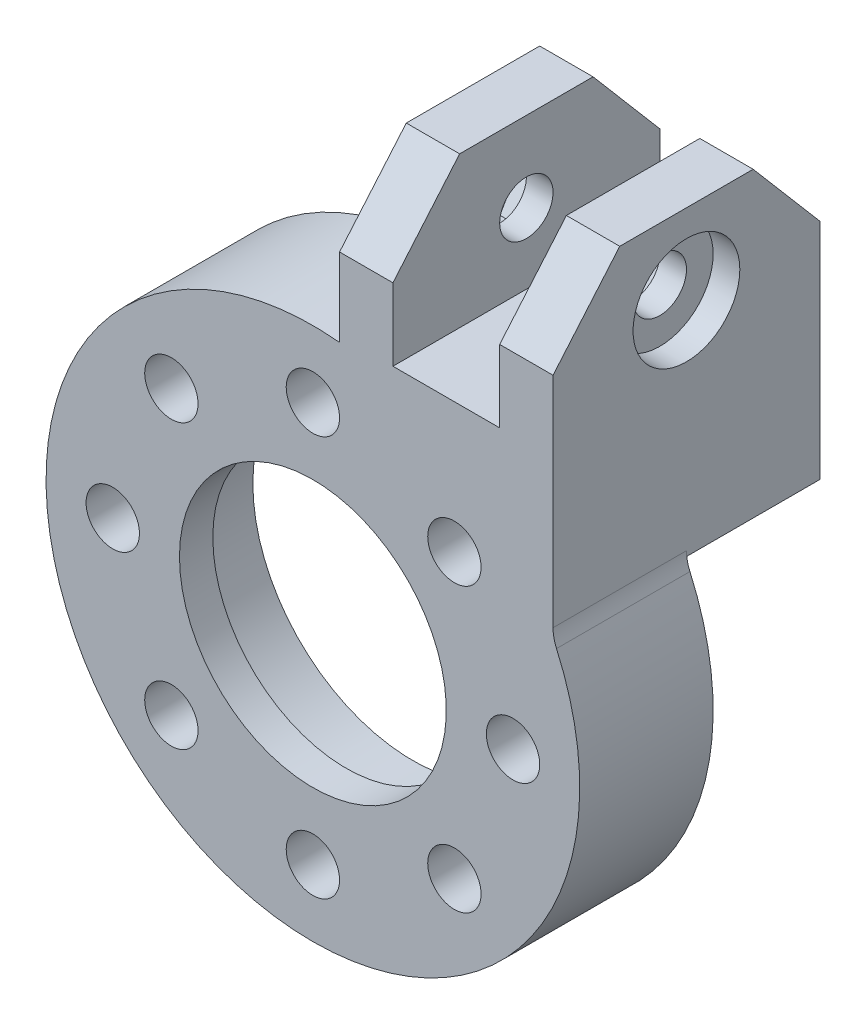
from build123d import *

# Parameters (mm, degrees)
SKETCH1_R               = 20
SKETCH1_R_2             = 15
BOSS_EXTRUDE1_DEPTH     = 10
BOSS_EXTRUDE2_DEPTH     = 20
SKETCH3_W               = 4
SKETCH3_H               = 31.92260483
BOSS_EXTRUDE4_DEPTH     = 20
BOSS_EXTRUDE5_DEPTH     = 20
SKETCH4_R               = 20
CUT_EXTRUDE1_DEPTH      = 11
CUT_EXTRUDE2_DEPTH      = 39
CUT_EXTRUDE3_DEPTH      = 39
SKETCH8_R               = 2
CUT_EXTRUDE4_DEPTH      = 39
FILLET4_R               = 3
SKETCH9_W               = 21.007104118
SKETCH9_H               = 10.314289307
CUT_EXTRUDE5_DEPTH      = 3
CUT_EXTRUDE5_DEPTH_BACK = 39
CUT_EXTRUDE6_DEPTH      = 19
CUT_EXTRUDE7_DEPTH      = 19
SKETCH12_R              = 4
CUT_EXTRUDE8_DEPTH      = 2
CUT_EXTRUDE9_DEPTH      = 2
BOSS_EXTRUDE7_DEPTH     = 20
SKETCH19_R              = 20.125
CUT_EXTRUDE11_DEPTH     = 11
SKETCH20_R              = 15
SKETCH20_R_2            = 12
BOSS_EXTRUDE8_DEPTH     = 10
SKETCH21_R              = 12
BOSS_EXTRUDE9_DEPTH     = 2.5
SKETCH22_R              = 10
CUT_EXTRUDE12_DEPTH     = 2.5
SKETCH23_R              = 17.5
CUT_EXTRUDE13_DEPTH     = 2.5
SKETCH24_R              = 2
CUT_EXTRUDE14_DEPTH     = 8.5


with BuildPart() as part:
    # Sketch1 → Boss-Extrude1 (new body)
    with BuildSketch(Plane.XY):
        Circle(SKETCH1_R)
        Circle(SKETCH1_R_2, mode=Mode.SUBTRACT)
    extrude(amount=BOSS_EXTRUDE1_DEPTH)

    # Sketch2 → Boss-Extrude2 (add)
    with BuildSketch(Plane.XY.offset(10)):
        with BuildLine():
            Line((2, 39.866068747), (2, 19.899748742))
            ThreePointArc((2, 19.899748742), (4.02100681, 19.591618214), (6, 19.078784028))
            Line((6, 19.078784028), (6, 39.866068747))
            Line((6, 39.866068747), (2, 39.866068747))
        make_face()
    extrude(amount=-BOSS_EXTRUDE2_DEPTH)

    # Sketch3 → Boss-Extrude4 (add)
    with BuildSketch(Plane.XY.offset(10)):
        with Locations((16, 24.679100302)):
            Rectangle(SKETCH3_W, SKETCH3_H)
    extrude(amount=-BOSS_EXTRUDE4_DEPTH)

    # Sketch5 → Boss-Extrude5 (add)
    with BuildSketch(Plane.XY.offset(10)):
        Polygon((14, 20.353512461), (10.603962903, 16.957475365), (14, 14.282856857), align=None)
    extrude(amount=-BOSS_EXTRUDE5_DEPTH)

    # Sketch4 → Cut-Extrude1 (cut, through all)
    with BuildSketch(Plane(origin=(0, 0, 0), x_dir=(-1, 0, 0), z_dir=(0, 0, -1))):
        Circle(SKETCH4_R)
    extrude(amount=CUT_EXTRUDE1_DEPTH, mode=Mode.SUBTRACT)

    # Sketch6 → Cut-Extrude2 (cut, through all)
    with BuildSketch(Plane(origin=(18, 0, 0), x_dir=(0, 0, -1), z_dir=(1, 0, 0))):
        Polygon((-10, 40.640402717), (-6, 40.640402717), (-10, 36.640402717), align=None)
    extrude(amount=-CUT_EXTRUDE2_DEPTH, mode=Mode.SUBTRACT)

    # Sketch7 → Cut-Extrude3 (cut, through all)
    with BuildSketch(Plane(origin=(18, 0, 0), x_dir=(0, 0, -1), z_dir=(1, 0, 0))):
        Polygon((10, 40.640402717), (6, 40.640402717), (10, 36.640402717), align=None)
    extrude(amount=-CUT_EXTRUDE3_DEPTH, mode=Mode.SUBTRACT)

    # Sketch8 → Cut-Extrude4 (cut, through all)
    with BuildSketch(Plane(origin=(18, 0, 0), x_dir=(0, 0, -1), z_dir=(1, 0, 0))):
        with Locations((0, 25.640402717)):
            Circle(SKETCH8_R)
    extrude(amount=-CUT_EXTRUDE4_DEPTH, mode=Mode.SUBTRACT)

    # Fillet4
    fillet4_edges = [part.edges().sort_by_distance(p)[0] for p in [
        (18, 8.717797887, 5),
    ]]
    fillet(fillet4_edges, radius=FILLET4_R)

    # Sketch9 → Cut-Extrude5 (cut, two sides)
    with BuildSketch(Plane(origin=(18, 0, 0), x_dir=(0, 0, -1), z_dir=(1, 0, 0))) as cut_extrude5_sk:
        with Locations((0.503552059, 36.79754737)):
            Rectangle(SKETCH9_W, SKETCH9_H)
    extrude(amount=CUT_EXTRUDE5_DEPTH, mode=Mode.SUBTRACT)
    extrude(cut_extrude5_sk.sketch, amount=-CUT_EXTRUDE5_DEPTH_BACK, mode=Mode.SUBTRACT)

    # Sketch10 → Cut-Extrude6 (cut, through all)
    with BuildSketch(Plane.ZY.offset(-2)):
        Polygon((10, 31.640402717), (5, 31.640402717), (10, 25.770075729), align=None)
    extrude(amount=-CUT_EXTRUDE6_DEPTH, mode=Mode.SUBTRACT)

    # Sketch11 → Cut-Extrude7 (cut, through all)
    with BuildSketch(Plane.ZY.offset(-2)):
        Polygon((-10, 31.640402717), (-10, 25.770075729), (-5, 31.640402717), align=None)
    extrude(amount=-CUT_EXTRUDE7_DEPTH, mode=Mode.SUBTRACT)

    # Sketch12 → Cut-Extrude8 (cut)
    with BuildSketch(Plane(origin=(18, 0, 0), x_dir=(0, 0, -1), z_dir=(1, 0, 0))):
        with Locations((0, 25.640402717)):
            Circle(SKETCH12_R)
    extrude(amount=-CUT_EXTRUDE8_DEPTH, mode=Mode.SUBTRACT)

    # Sketch13 → Cut-Extrude9 (cut)
    with BuildSketch(Plane.ZY.offset(-2)):
        Polygon((4.041451884, 25.640402717), (2.020725942, 29.140402717), (-2.020725942, 29.140402717), (-4.041451884, 25.640402717), (-2.020725942, 22.140402717), (2.020725942, 22.140402717), align=None)
    extrude(amount=-CUT_EXTRUDE9_DEPTH, mode=Mode.SUBTRACT)

    # Sketch16 → Boss-Extrude7 (add)
    with BuildSketch(Plane.XY.offset(10)):
        with BuildLine():
            Line((14, 20.353512461), (6, 20.353512461))
            Line((6, 20.353512461), (6, 19.078784028))
            ThreePointArc((6, 19.078784028), (8.369461371, 18.164584123), (10.603962903, 16.957475365))
            Line((10.603962903, 16.957475365), (14, 20.353512461))
        make_face()
    extrude(amount=-BOSS_EXTRUDE7_DEPTH)

    # Sketch19 → Cut-Extrude11 (cut, through all)
    with BuildSketch(Plane(origin=(0, 0, 0), x_dir=(-1, 0, 0), z_dir=(0, 0, -1))):
        Circle(SKETCH19_R)
    extrude(amount=CUT_EXTRUDE11_DEPTH, mode=Mode.SUBTRACT)

    # Sketch20 → Boss-Extrude8 (add)
    with BuildSketch(Plane.XY.offset(10)):
        Circle(SKETCH20_R)
        Circle(SKETCH20_R_2, mode=Mode.SUBTRACT)
    extrude(amount=-BOSS_EXTRUDE8_DEPTH)

    # Sketch21 → Boss-Extrude9 (add)
    with BuildSketch(Plane.XY.offset(10)):
        Circle(SKETCH21_R)
    extrude(amount=-BOSS_EXTRUDE9_DEPTH)

    # Sketch22 → Cut-Extrude12 (cut)
    with BuildSketch(Plane(origin=(0, 0, 7.5), x_dir=(-1, 0, 0), z_dir=(0, 0, -1))):
        Circle(SKETCH22_R)
    extrude(amount=-CUT_EXTRUDE12_DEPTH, mode=Mode.SUBTRACT)

    # Sketch23 → Cut-Extrude13 (cut)
    with BuildSketch(Plane(origin=(0, 0, 0), x_dir=(-1, 0, 0), z_dir=(0, 0, -1))):
        Circle(SKETCH23_R)
    extrude(amount=-CUT_EXTRUDE13_DEPTH, mode=Mode.SUBTRACT)

    # Sketch24 → Cut-Extrude14 (cut, through all)
    with BuildSketch(Plane(origin=(0, 0, 2.5), x_dir=(-1, 0, 0), z_dir=(0, 0, -1))):
        with Locations((0, 15)):
            Circle(SKETCH24_R)
        with Locations((10.606601718, 10.606601718)):
            Circle(SKETCH24_R)
        with Locations((15, 0)):
            Circle(SKETCH24_R)
        with Locations((10.606601718, -10.606601718)):
            Circle(SKETCH24_R)
        with Locations((0, -15)):
            Circle(SKETCH24_R)
        with Locations((-10.606601718, -10.606601718)):
            Circle(SKETCH24_R)
        with Locations((-15, 0)):
            Circle(SKETCH24_R)
        with Locations((-10.606601718, 10.606601718)):
            Circle(SKETCH24_R)
    extrude(amount=-CUT_EXTRUDE14_DEPTH, mode=Mode.SUBTRACT)


solid = part.part
